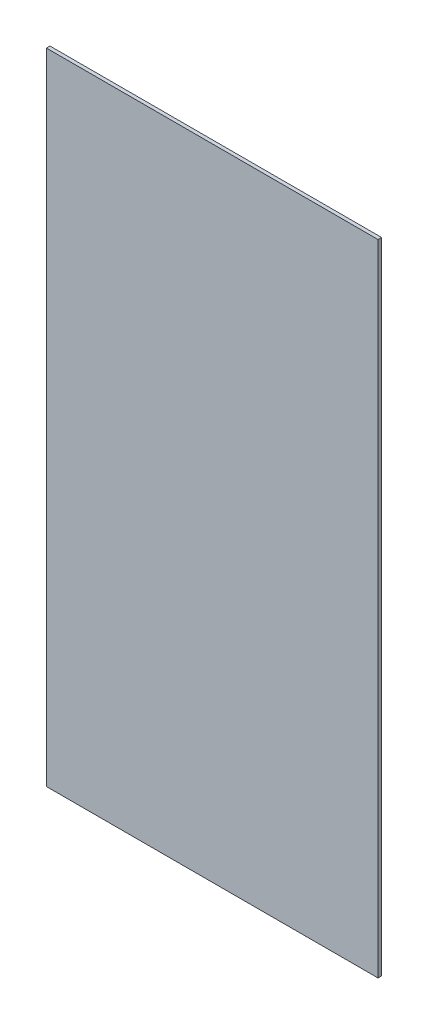
from build123d import *

# Parameters (mm, degrees)
ESQUISSE1_W        = 280
ESQUISSE1_H        = 540
BOSS_EXTRU_1_DEPTH = 3


with BuildPart() as part:
    # Esquisse1 → Boss.-Extru.1 (new body)
    with BuildSketch(Plane.XY):
        with Locations((62.570941439, -183.299446884)):
            Rectangle(ESQUISSE1_W, ESQUISSE1_H)
    extrude(amount=BOSS_EXTRU_1_DEPTH)


solid = part.part
